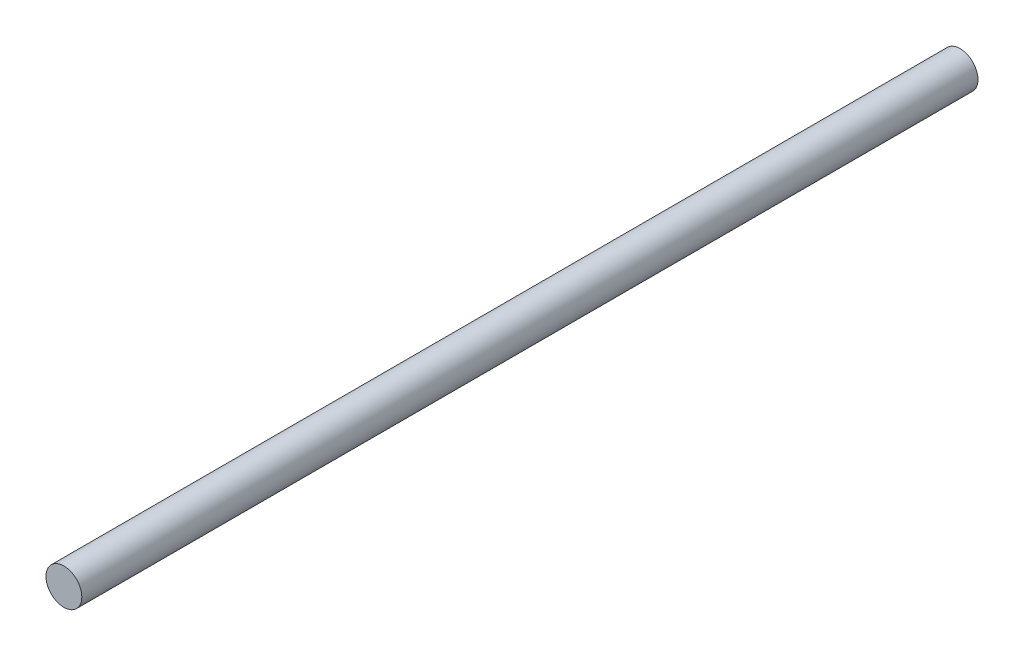
from build123d import *

# Parameters (mm, degrees)
SKETCH1_R           = 4
BOSS_EXTRUDE1_DEPTH = 200


with BuildPart() as part:
    # Sketch1 → Boss-Extrude1 (new body)
    with BuildSketch(Plane.XY):
        Circle(SKETCH1_R)
    extrude(amount=BOSS_EXTRUDE1_DEPTH)


solid = part.part
